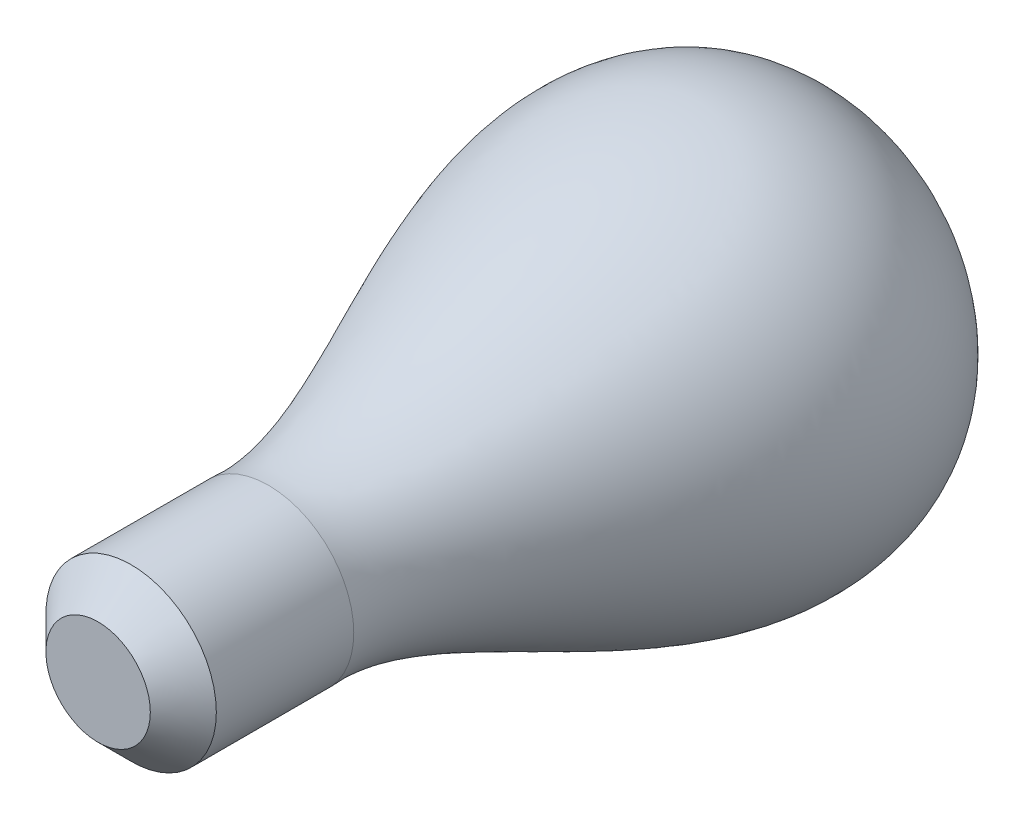
from build123d import *

# Parameters (mm, degrees)
SKETCH1_R           = 12.7
BOSS_EXTRUDE1_DEPTH = 25.4
CHAMFER1_SIZE       = 4.92


with BuildPart() as part:
    # Sketch1 → Boss-Extrude1 (new body)
    with BuildSketch(Plane.XY):
        Circle(SKETCH1_R)
    extrude(amount=BOSS_EXTRUDE1_DEPTH)

    # Sketch2 → Revolve1 (revolve)
    with BuildSketch(Plane(origin=(0, 0, 0), x_dir=(1, 0, 0), z_dir=(0, 1, 0))):
        with BuildLine():
            Line((0, 0), (0, 91.44))
            add(Edge.make_bspline(
                [(0, 91.44), (-22.313297432, 89.869472139), (-44.030480488, 54.776848914), (-11.128878032, 19.035751287), (-12.7, 0)],
                knots=[0, 0, 0, 0, 0.356051471, 1, 1, 1, 1], degree=3))
            Line((-12.7, 0), (0, 0))
        make_face()
    revolve(axis=Axis((0, 0, 0), (0, 0, -1)))

    # Chamfer1
    chamfer1_edges = [part.edges().sort_by_distance(p)[0] for p in [
        (-12.7, 0, 25.4),
    ]]
    chamfer(chamfer1_edges, length=CHAMFER1_SIZE)


solid = part.part
